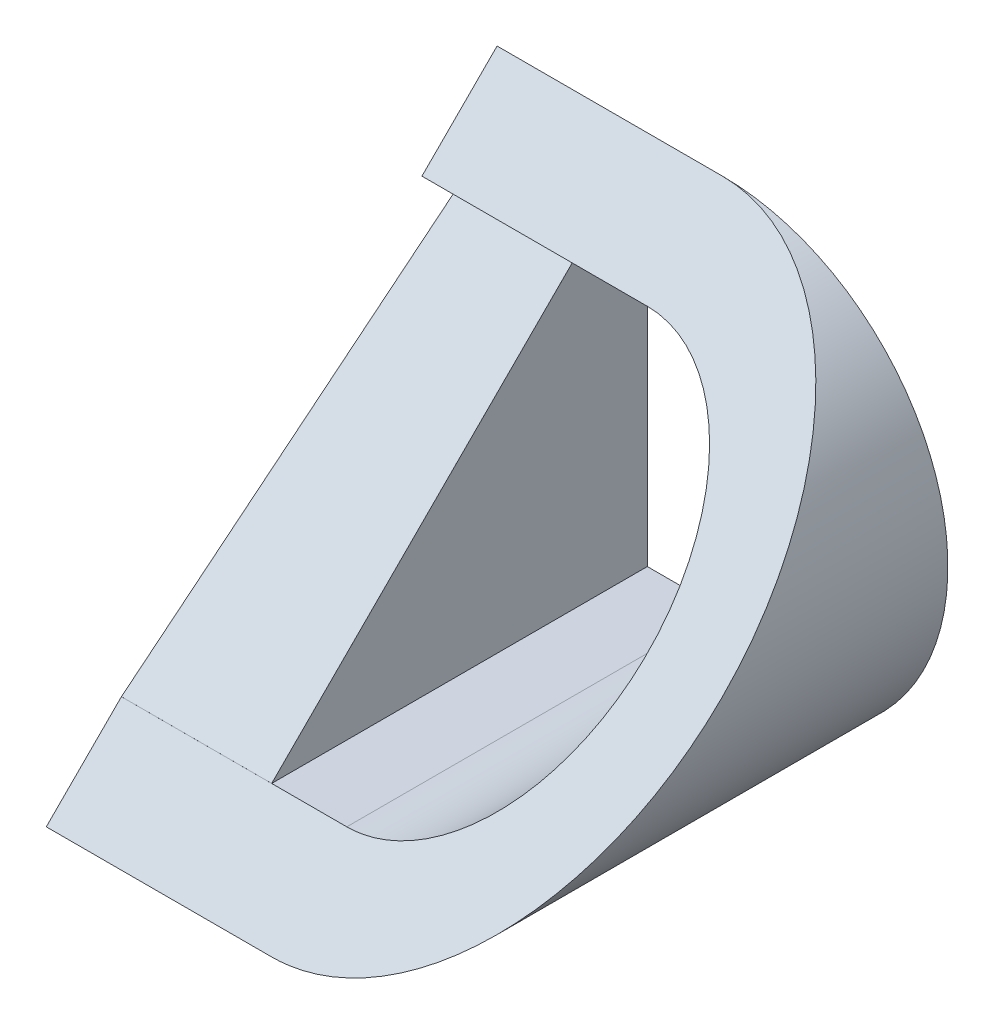
from build123d import *

# Parameters (mm, degrees)
SKETCH1_W           = 30
SKETCH1_H           = 60
BOSS_EXTRUDE1_DEPTH = 60
CUT_EXTRUDE1_DEPTH  = 60
SKETCH4_W           = 20
SKETCH4_H           = 40
CUT_EXTRUDE2_DEPTH  = 60
CUT_EXTRUDE3_DEPTH  = 60
BOSS_EXTRUDE2_DEPTH = 20
CUT_EXTRUDE9_DEPTH  = 20


with BuildPart() as part:
    # Sketch1 → Boss-Extrude1 (new body)
    with BuildSketch(Plane.XY):
        with BuildLine():
            ThreePointArc((30, 60), (60, 30), (30, 0))
            Line((30, 0), (30, 60))
        make_face()
        with Locations((15, 30)):
            Rectangle(SKETCH1_W, SKETCH1_H)
    extrude(amount=BOSS_EXTRUDE1_DEPTH)

    # Sketch2 → Cut-Extrude1 (cut)
    with BuildSketch(Plane.ZY):
        Polygon((0, 60), (60, 0), (60, 60), align=None)
    extrude(amount=-CUT_EXTRUDE1_DEPTH, mode=Mode.SUBTRACT)

    # Sketch4 → Cut-Extrude2 (cut)
    with BuildSketch(Plane(origin=(0, 0, 0), x_dir=(-1, 0, 0), z_dir=(0, 0, -1))):
        with Locations((-10.0001, 30)):
            Rectangle(SKETCH4_W, SKETCH4_H)
    extrude(amount=-CUT_EXTRUDE2_DEPTH, mode=Mode.SUBTRACT)

    # Sketch5 → Cut-Extrude3 (cut)
    with BuildSketch(Plane(origin=(0, 0, 0), x_dir=(-1, 0, 0), z_dir=(0, 0, -1))):
        with BuildLine():
            Line((-30, 50), (-20.0003, 50))
            Line((-20.0003, 50), (-20.0003, 10.000000002))
            Line((-20.0003, 10.000000002), (-30.0003, 10.000000002))
            ThreePointArc((-30.0003, 10.000000002), (-49.999999999, 30.00015), (-30, 50))
        make_face()
    extrude(amount=-CUT_EXTRUDE3_DEPTH, mode=Mode.SUBTRACT)

    # Sketch6 → Boss-Extrude2 (add)
    with BuildSketch(Plane.ZY.offset(-20.0001)):
        Polygon((0, 50.000000001), (9.999999999, 50.000000001), (50, 10), (0, 10), align=None)
    extrude(amount=BOSS_EXTRUDE2_DEPTH)

    # Sketch7 → Cut-Extrude9 (cut)
    with BuildSketch(Plane.ZY):
        Polygon((49.999999998, 10.000000002), (49.996907355, 10.000000002), (0.748306112, 50), (10, 50), align=None)
    extrude(amount=-CUT_EXTRUDE9_DEPTH, mode=Mode.SUBTRACT)


solid = part.part
